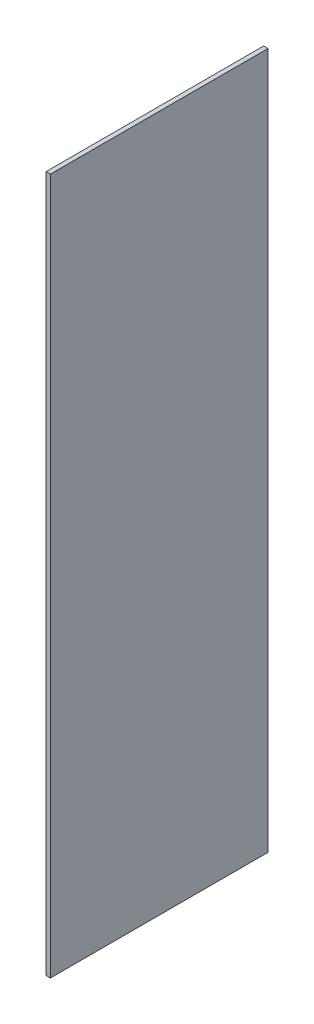
from build123d import *

# Parameters (mm, degrees)
SKETCH1_W           = 0.1
SKETCH1_H           = 16
BOSS_EXTRUDE1_DEPTH = 5


with BuildPart() as part:
    # Sketch1 → Boss-Extrude1 (new body)
    with BuildSketch(Plane.XY):
        with Locations((0.05, 8)):
            Rectangle(SKETCH1_W, SKETCH1_H)
    extrude(amount=BOSS_EXTRUDE1_DEPTH)


solid = part.part
